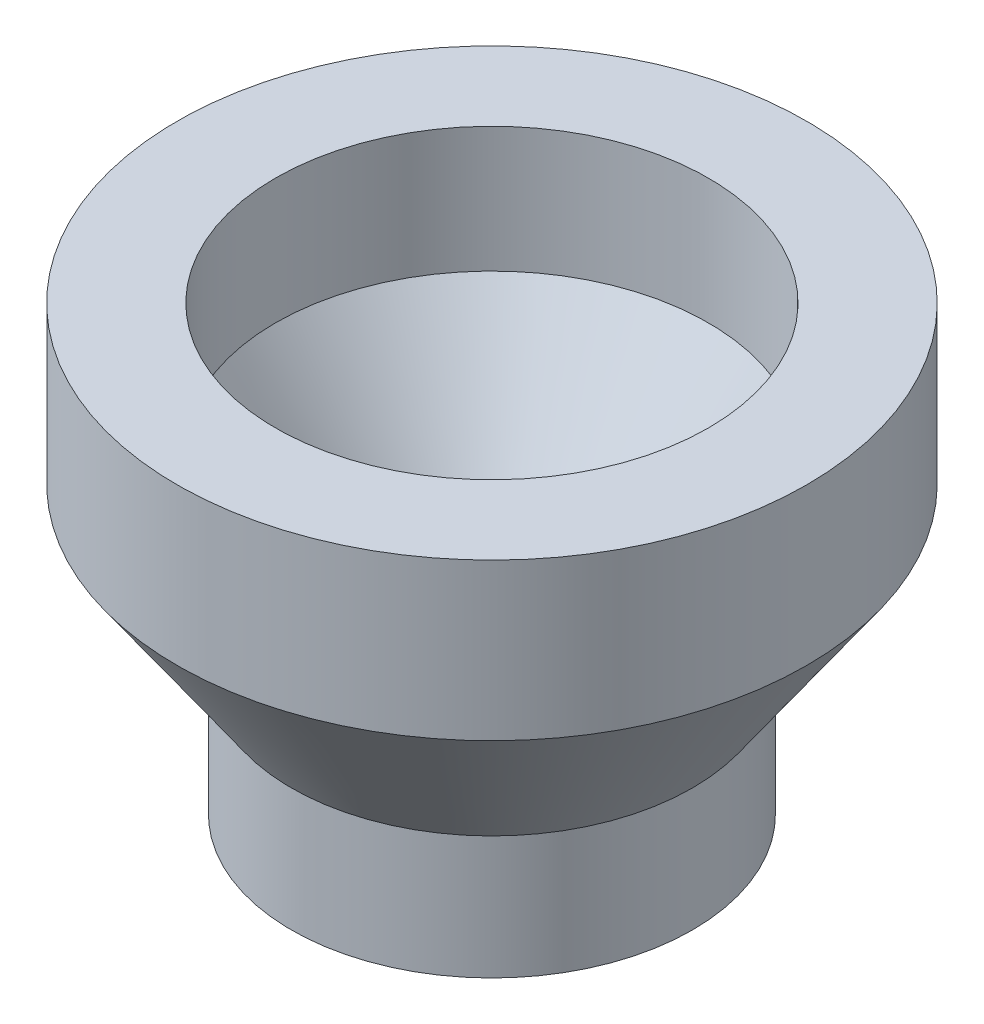
from build123d import *


with BuildPart() as part:
    # Sketch1 → Revolve1 (revolve)
    with BuildSketch(Plane.XY):
        Polygon((-2.575, 34.790118513), (-4.075, 34.790118513), (-4.075, 37.290118513), (-6.4, 40.610562628), (-6.4, 43.790118513), (-4.4, 43.790118513), (-4.4, 41.241160206), (-2.575, 38.634790094), align=None)
    revolve(axis=Axis((0, 9.790118513, 0), (0, 1, 0)))


solid = part.part
